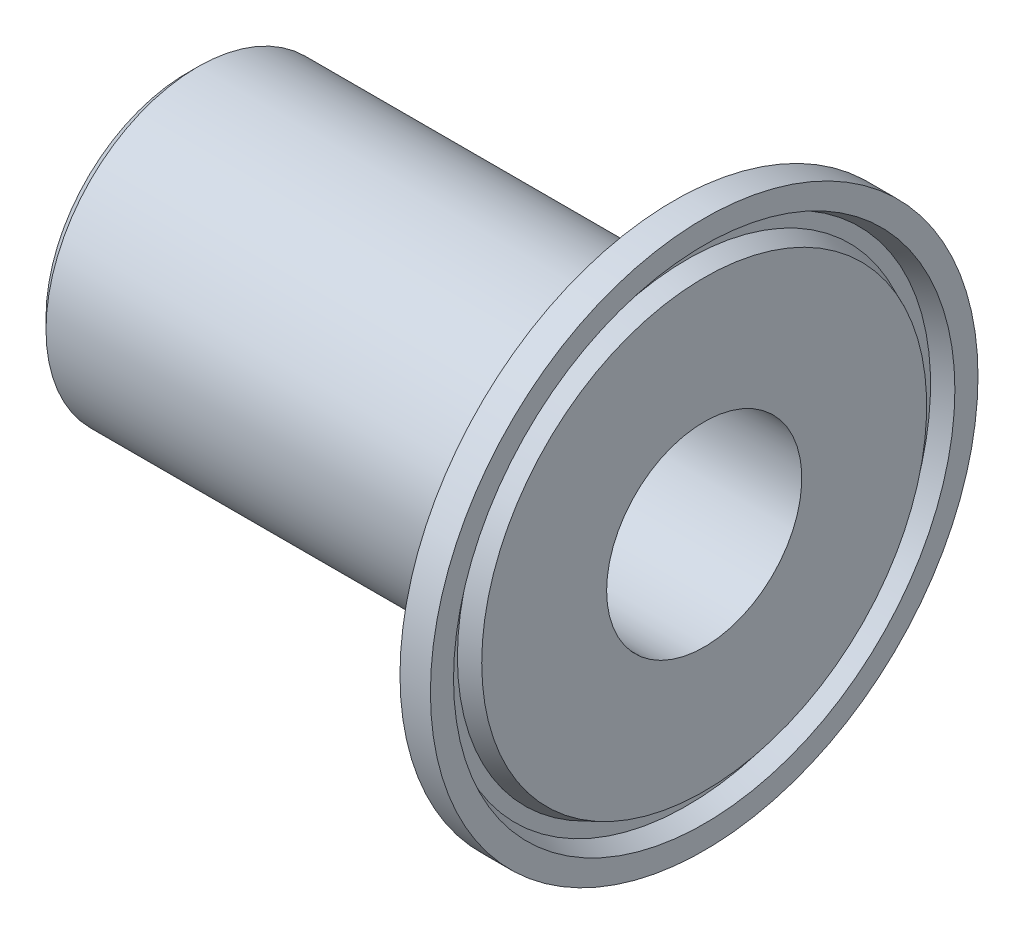
from build123d import *

# Parameters (mm, degrees)
CHAMFER3_SIZE = 1


with BuildPart() as part:
    # Sketch1 → Revolve1 (revolve)
    with BuildSketch(Plane.XY):
        with BuildLine():
            Line((41.074068666, 14.752070976), (44.895002352, 25.25))
            Line((44.895002352, 25.25), (47.701702352, 25.25))
            Line((47.701702352, 25.25), (47.701702352, 23.1186))
            Line((47.701702352, 23.1186), (46.126902352, 22.450137059))
            Line((46.126902352, 22.450137059), (46.126902352, 21.187062941))
            Line((46.126902352, 21.187062941), (47.701702352, 20.5186))
            Line((47.701702352, 20.5186), (47.701702352, 9))
            Line((47.701702352, 9), (0, 9))
            Line((0, 9), (0, 14))
            Line((0, 14), (40, 14))
            ThreePointArc((40, 14), (40.655597867, 14.206709213), (41.074068666, 14.752070976))
        make_face()
    revolve(axis=Axis((0, 0, 0), (1, 0, 0)))

    # Chamfer3
    chamfer3_edges = [part.edges().sort_by_distance(p)[0] for p in [
        (0, -14, 0),
    ]]
    chamfer(chamfer3_edges, length=CHAMFER3_SIZE)


solid = part.part
